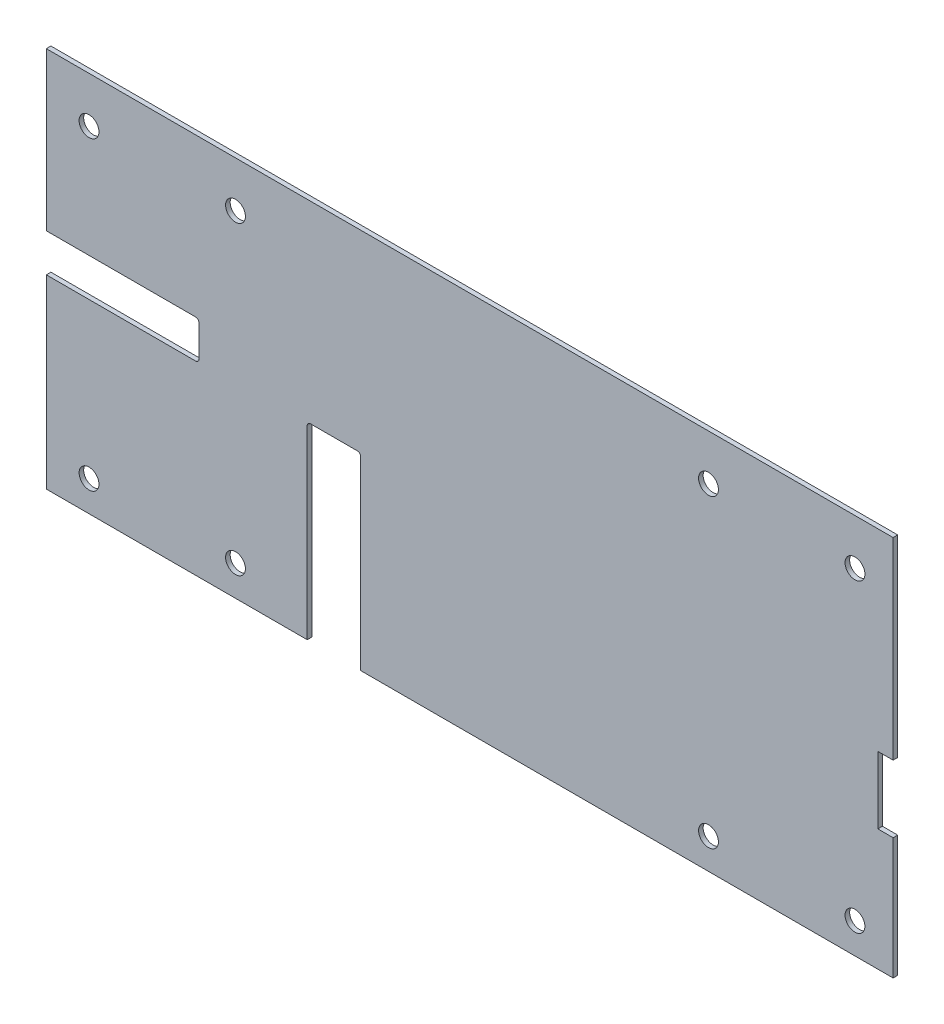
from build123d import *

# Parameters (mm, degrees)
ESQUISSE1_W             = 555
ESQUISSE1_H             = 250
ESQUISSE1_R             = 6.5
BOSS_EXTRU_1_DEPTH      = 3
ESQUISSE4_W             = 100
ESQUISSE4_H             = 25
ESQUISSE4_W_2           = 35
ESQUISSE4_H_2           = 123.628962184
ESQUISSE4_W_3           = 10
ESQUISSE4_H_3           = 44
ENL_V_MAT_EXTRU_3_DEPTH = 10
CONG_1_R                = 2


with BuildPart() as part:
    # Esquisse1 → Boss.-Extru.1 (new body)
    with BuildSketch(Plane.XY):
        Rectangle(ESQUISSE1_W, ESQUISSE1_H)
        with Locations((156.5, 95)):
            Circle(ESQUISSE1_R, mode=Mode.SUBTRACT)
        with Locations((252.5, 95)):
            Circle(ESQUISSE1_R, mode=Mode.SUBTRACT)
        with Locations((156.5, -105)):
            Circle(ESQUISSE1_R, mode=Mode.SUBTRACT)
        with Locations((252.5, -105)):
            Circle(ESQUISSE1_R, mode=Mode.SUBTRACT)
        with Locations((-153.5, -105)):
            Circle(ESQUISSE1_R, mode=Mode.SUBTRACT)
        with Locations((-153.5, 95)):
            Circle(ESQUISSE1_R, mode=Mode.SUBTRACT)
        with Locations((-249.5, 95)):
            Circle(ESQUISSE1_R, mode=Mode.SUBTRACT)
        with Locations((-249.5, -105)):
            Circle(ESQUISSE1_R, mode=Mode.SUBTRACT)
    extrude(amount=BOSS_EXTRU_1_DEPTH)

    # Esquisse4 → Enlèv. mat.-Extru.3 (cut)
    with BuildSketch(Plane.XY.offset(3)):
        with Locations((-227.5, 9.128962184)):
            Rectangle(ESQUISSE4_W, ESQUISSE4_H)
        with Locations((-89, -63.185518908)):
            Rectangle(ESQUISSE4_W_2, ESQUISSE4_H_2)
        with Locations((272.5, -23.371037816)):
            Rectangle(ESQUISSE4_W_3, ESQUISSE4_H_3)
    extrude(amount=-ENL_V_MAT_EXTRU_3_DEPTH, mode=Mode.SUBTRACT)

    # Congé1
    cong_1_edges = [part.edges().sort_by_distance(p)[0] for p in [
        (-177.5, 21.628962184, 1.5),
        (-177.5, -3.371037816, 1.5),
        (-106.5, -1.371037816, 1.5),
        (-71.5, -1.371037816, 1.5),
    ]]
    fillet(cong_1_edges, radius=CONG_1_R)


solid = part.part
